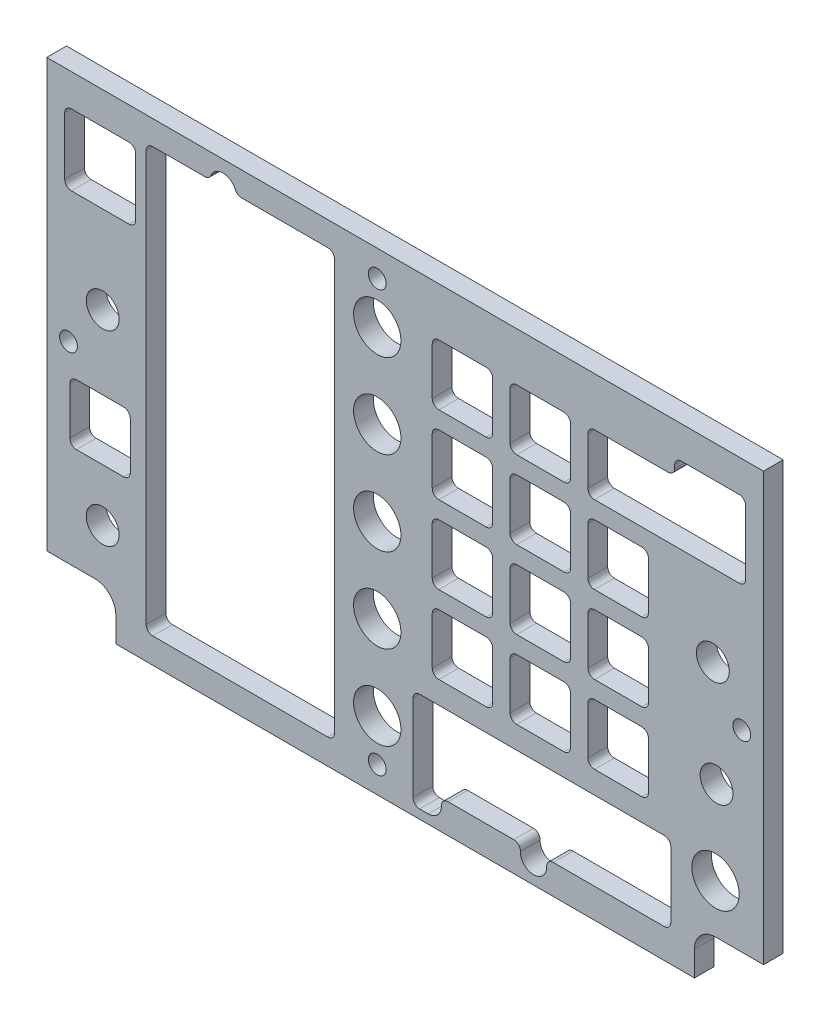
from build123d import *

# Parameters (mm, degrees)
BOSS_EXTRUDE1_DEPTH     = 4.7625
SKETCH4_R               = 3.96875
CUT_EXTRUDE2_DEPTH      = 5.7625
F_6_CLEARANCE_HOLE2_D   = 4.3053
SKETCH15_R              = 5.715
CUT_EXTRUDE8_DEPTH      = 1
CUT_EXTRUDE8_DEPTH_BACK = 5.7625


with BuildPart() as part:
    # Sketch1 → Boss-Extrude1 (new body)
    with BuildSketch(Plane.XY):
        with BuildLine():
            Line((74.93, -171.1167297), (86.51875, -171.1167297))
            Line((86.51875, -171.1167297), (86.51875, -67.9292297))
            Line((86.51875, -67.9292297), (-86.51875, -67.9292297))
            Line((-86.51875, -67.9292297), (-86.51875, -171.1167297))
            Line((-86.51875, -171.1167297), (-74.93, -171.1167297))
            ThreePointArc((-74.93, -171.1167297), (-71.337897552, -172.604627251), (-69.85, -176.1967297))
            Line((-69.85, -176.1967297), (-69.85, -182.2292297))
            Line((-69.85, -182.2292297), (69.85, -182.2292297))
            Line((69.85, -182.2292297), (69.85, -176.1967297))
            ThreePointArc((69.85, -176.1967297), (71.337897552, -172.604627251), (74.93, -171.1167297))
        make_face()
    extrude(amount=-BOSS_EXTRUDE1_DEPTH)

    # Sketch4 → Cut-Extrude2 (cut, through all)
    with BuildSketch(Plane.XY):
        with Locations((-73.025, -113.9667297)):
            Circle(SKETCH4_R)
        with Locations((-73.025, -159.0517297)):
            Circle(SKETCH4_R)
        with Locations((74.295, -113.9667297)):
            Circle(SKETCH4_R)
        with Locations((75.184, -139.0492297)):
            Circle(SKETCH4_R)
    extrude(amount=-CUT_EXTRUDE2_DEPTH, mode=Mode.SUBTRACT)

    # #6 Clearance Hole2 (through all)
    with Locations(Plane(origin=(0, 0, 1.5875), x_dir=(-1, 0, 0), z_dir=(0, 0, 1))):
        with Locations((-81.28, 124.6982297), (6.731, 175.8792297), (81.28, 124.6982297), (6.731, 74.2792297)):
            Hole(F_6_CLEARANCE_HOLE2_D / 2)

    # Sketch15 → Cut-Extrude8 (cut, two sides)
    with BuildSketch(Plane(origin=(0, 0, -4.7625), x_dir=(-1, 0, 0), z_dir=(0, 0, -1))) as cut_extrude8_sk:
        with Locations((-74.93, -159.3692297)):
            Circle(SKETCH15_R)
        with Locations((6.731, -84.4392297)):
            Circle(SKETCH15_R)
        with Locations((6.731, -104.7592297)):
            Circle(SKETCH15_R)
        with Locations((6.731, -125.0792297)):
            Circle(SKETCH15_R)
        with Locations((6.731, -145.3992297)):
            Circle(SKETCH15_R)
        with Locations((6.731, -165.7192297)):
            Circle(SKETCH15_R)
        with BuildLine():
            Line((-58.7375, -137.6522297), (-58.7375, -149.0822297))
            ThreePointArc((-58.7375, -149.0822297), (-58.272532015, -150.204761715), (-57.15, -150.6697297))
            Line((-57.15, -150.6697297), (-45.72, -150.6697297))
            ThreePointArc((-45.72, -150.6697297), (-44.597467985, -150.204761715), (-44.1325, -149.0822297))
            Line((-44.1325, -149.0822297), (-44.1325, -137.6522297))
            ThreePointArc((-44.1325, -137.6522297), (-44.597467985, -136.529697685), (-45.72, -136.0647297))
            Line((-45.72, -136.0647297), (-57.15, -136.0647297))
            ThreePointArc((-57.15, -136.0647297), (-58.272532015, -136.529697685), (-58.7375, -137.6522297))
        make_face()
        with BuildLine():
            Line((-58.7375, -118.8562297), (-58.7375, -130.2862297))
            ThreePointArc((-58.7375, -130.2862297), (-58.272532015, -131.408761715), (-57.15, -131.8737297))
            Line((-57.15, -131.8737297), (-45.72, -131.8737297))
            ThreePointArc((-45.72, -131.8737297), (-44.597467985, -131.408761715), (-44.1325, -130.2862297))
            Line((-44.1325, -130.2862297), (-44.1325, -118.8562297))
            ThreePointArc((-44.1325, -118.8562297), (-44.597467985, -117.733697685), (-45.72, -117.2687297))
            Line((-45.72, -117.2687297), (-57.15, -117.2687297))
            ThreePointArc((-57.15, -117.2687297), (-58.272532015, -117.733697685), (-58.7375, -118.8562297))
        make_face()
        with BuildLine():
            Line((-58.7375, -100.0602297), (-58.7375, -111.4902297))
            ThreePointArc((-58.7375, -111.4902297), (-58.272532015, -112.612761715), (-57.15, -113.0777297))
            Line((-57.15, -113.0777297), (-45.72, -113.0777297))
            ThreePointArc((-45.72, -113.0777297), (-44.597467985, -112.612761715), (-44.1325, -111.4902297))
            Line((-44.1325, -111.4902297), (-44.1325, -100.0602297))
            ThreePointArc((-44.1325, -100.0602297), (-44.597467985, -98.937697685), (-45.72, -98.4727297))
            Line((-45.72, -98.4727297), (-57.15, -98.4727297))
            ThreePointArc((-57.15, -98.4727297), (-58.272532015, -98.937697685), (-58.7375, -100.0602297))
        make_face()
        with BuildLine():
            Line((-45.72, -79.6767297), (-63.488214902, -79.6767297))
            ThreePointArc((-63.488214902, -79.6767297), (-64.610746917, -79.211761715), (-65.075714902, -78.0892297))
            Line((-65.075714902, -78.0892297), (-65.075714902, -77.3272297))
            ThreePointArc((-65.075714902, -77.3272297), (-65.540682887, -76.204697685), (-66.663214902, -75.7397297))
            Line((-66.663214902, -75.7397297), (-80.633214902, -75.7397297))
            ThreePointArc((-80.633214902, -75.7397297), (-81.755746917, -76.204697685), (-82.220714902, -77.3272297))
            Line((-82.220714902, -77.3272297), (-82.220714902, -92.6942297))
            ThreePointArc((-82.220714902, -92.6942297), (-81.755746917, -93.816761715), (-80.633214902, -94.2817297))
            Line((-80.633214902, -94.2817297), (-45.72, -94.2817297))
            ThreePointArc((-45.72, -94.2817297), (-44.597467985, -93.816761715), (-44.1325, -92.6942297))
            Line((-44.1325, -92.6942297), (-44.1325, -81.2642297))
            ThreePointArc((-44.1325, -81.2642297), (-44.597467985, -80.141697685), (-45.72, -79.6767297))
        make_face()
        with BuildLine():
            Line((-39.9415, -81.2642297), (-39.9415, -92.6942297))
            ThreePointArc((-39.9415, -92.6942297), (-39.476532015, -93.816761715), (-38.354, -94.2817297))
            Line((-38.354, -94.2817297), (-26.924, -94.2817297))
            ThreePointArc((-26.924, -94.2817297), (-25.801467985, -93.816761715), (-25.3365, -92.6942297))
            Line((-25.3365, -92.6942297), (-25.3365, -81.2642297))
            ThreePointArc((-25.3365, -81.2642297), (-25.801467985, -80.141697685), (-26.924, -79.6767297))
            Line((-26.924, -79.6767297), (-38.354, -79.6767297))
            ThreePointArc((-38.354, -79.6767297), (-39.476532015, -80.141697685), (-39.9415, -81.2642297))
        make_face()
        with BuildLine():
            Line((-39.9415, -100.0602297), (-39.9415, -111.4902297))
            ThreePointArc((-39.9415, -111.4902297), (-39.476532015, -112.612761715), (-38.354, -113.0777297))
            Line((-38.354, -113.0777297), (-26.924, -113.0777297))
            ThreePointArc((-26.924, -113.0777297), (-25.801467985, -112.612761715), (-25.3365, -111.4902297))
            Line((-25.3365, -111.4902297), (-25.3365, -100.0602297))
            ThreePointArc((-25.3365, -100.0602297), (-25.801467985, -98.937697685), (-26.924, -98.4727297))
            Line((-26.924, -98.4727297), (-38.354, -98.4727297))
            ThreePointArc((-38.354, -98.4727297), (-39.476532015, -98.937697685), (-39.9415, -100.0602297))
        make_face()
        with BuildLine():
            Line((-39.9415, -118.8562297), (-39.9415, -130.2862297))
            ThreePointArc((-39.9415, -130.2862297), (-39.476532015, -131.408761715), (-38.354, -131.8737297))
            Line((-38.354, -131.8737297), (-26.924, -131.8737297))
            ThreePointArc((-26.924, -131.8737297), (-25.801467985, -131.408761715), (-25.3365, -130.2862297))
            Line((-25.3365, -130.2862297), (-25.3365, -118.8562297))
            ThreePointArc((-25.3365, -118.8562297), (-25.801467985, -117.733697685), (-26.924, -117.2687297))
            Line((-26.924, -117.2687297), (-38.354, -117.2687297))
            ThreePointArc((-38.354, -117.2687297), (-39.476532015, -117.733697685), (-39.9415, -118.8562297))
        make_face()
        with BuildLine():
            Line((-39.9415, -137.6522297), (-39.9415, -149.0822297))
            ThreePointArc((-39.9415, -149.0822297), (-39.476532015, -150.204761715), (-38.354, -150.6697297))
            Line((-38.354, -150.6697297), (-26.924, -150.6697297))
            ThreePointArc((-26.924, -150.6697297), (-25.801467985, -150.204761715), (-25.3365, -149.0822297))
            Line((-25.3365, -149.0822297), (-25.3365, -137.6522297))
            ThreePointArc((-25.3365, -137.6522297), (-25.801467985, -136.529697685), (-26.924, -136.0647297))
            Line((-26.924, -136.0647297), (-38.354, -136.0647297))
            ThreePointArc((-38.354, -136.0647297), (-39.476532015, -136.529697685), (-39.9415, -137.6522297))
        make_face()
        with BuildLine():
            Line((-26.230517255, -175.1172297), (-10.349482745, -175.1172297))
            ThreePointArc((-10.349482745, -175.1172297), (-9.207149606, -175.602354423), (-8.762988497, -176.7612297))
            ThreePointArc((-8.762988497, -176.7612297), (-7.874666278, -179.078980253), (-5.59, -180.0492297))
            Line((-5.59, -180.0492297), (-3.4925, -180.0492297))
            ThreePointArc((-3.4925, -180.0492297), (-2.369967985, -179.584261715), (-1.905, -178.4617297))
            Line((-1.905, -178.4617297), (-1.905, -157.6547297))
            ThreePointArc((-1.905, -157.6547297), (-2.369967985, -156.532197685), (-3.4925, -156.0672297))
            Line((-3.4925, -156.0672297), (-62.5475, -156.0672297))
            ThreePointArc((-62.5475, -156.0672297), (-63.670032015, -156.532197685), (-64.135, -157.6547297))
            Line((-64.135, -157.6547297), (-64.135, -173.5297297))
            ThreePointArc((-64.135, -173.5297297), (-63.670032015, -174.652261715), (-62.5475, -175.1172297))
            Line((-62.5475, -175.1172297), (-35.749482745, -175.1172297))
            ThreePointArc((-35.749482745, -175.1172297), (-34.607149606, -175.602354423), (-34.162988497, -176.7612297))
            ThreePointArc((-34.162988497, -176.7612297), (-30.99, -180.0492297), (-27.817011503, -176.7612297))
            ThreePointArc((-27.817011503, -176.7612297), (-27.372850394, -175.602354423), (-26.230517255, -175.1172297))
        make_face()
        with BuildLine():
            Line((-6.5405, -149.0822297), (-6.5405, -137.6522297))
            ThreePointArc((-6.5405, -137.6522297), (-7.005467985, -136.529697685), (-8.128, -136.0647297))
            Line((-8.128, -136.0647297), (-19.558, -136.0647297))
            ThreePointArc((-19.558, -136.0647297), (-20.680532015, -136.529697685), (-21.1455, -137.6522297))
            Line((-21.1455, -137.6522297), (-21.1455, -149.0822297))
            ThreePointArc((-21.1455, -149.0822297), (-20.680532015, -150.204761715), (-19.558, -150.6697297))
            Line((-19.558, -150.6697297), (-8.128, -150.6697297))
            ThreePointArc((-8.128, -150.6697297), (-7.005467985, -150.204761715), (-6.5405, -149.0822297))
        make_face()
        with BuildLine():
            Line((-6.5405, -130.2862297), (-6.5405, -118.8562297))
            ThreePointArc((-6.5405, -118.8562297), (-7.005467985, -117.733697685), (-8.128, -117.2687297))
            Line((-8.128, -117.2687297), (-19.558, -117.2687297))
            ThreePointArc((-19.558, -117.2687297), (-20.680532015, -117.733697685), (-21.1455, -118.8562297))
            Line((-21.1455, -118.8562297), (-21.1455, -130.2862297))
            ThreePointArc((-21.1455, -130.2862297), (-20.680532015, -131.408761715), (-19.558, -131.8737297))
            Line((-19.558, -131.8737297), (-8.128, -131.8737297))
            ThreePointArc((-8.128, -131.8737297), (-7.005467985, -131.408761715), (-6.5405, -130.2862297))
        make_face()
        with BuildLine():
            Line((-21.1455, -100.0602297), (-21.1455, -111.4902297))
            ThreePointArc((-21.1455, -111.4902297), (-20.680532015, -112.612761715), (-19.558, -113.0777297))
            Line((-19.558, -113.0777297), (-8.128, -113.0777297))
            ThreePointArc((-8.128, -113.0777297), (-7.005467985, -112.612761715), (-6.5405, -111.4902297))
            Line((-6.5405, -111.4902297), (-6.5405, -100.0602297))
            ThreePointArc((-6.5405, -100.0602297), (-7.005467985, -98.937697685), (-8.128, -98.4727297))
            Line((-8.128, -98.4727297), (-19.558, -98.4727297))
            ThreePointArc((-19.558, -98.4727297), (-20.680532015, -98.937697685), (-21.1455, -100.0602297))
        make_face()
        with BuildLine():
            Line((-21.1455, -81.2642297), (-21.1455, -92.6942297))
            ThreePointArc((-21.1455, -92.6942297), (-20.680532015, -93.816761715), (-19.558, -94.2817297))
            Line((-19.558, -94.2817297), (-8.128, -94.2817297))
            ThreePointArc((-8.128, -94.2817297), (-7.005467985, -93.816761715), (-6.5405, -92.6942297))
            Line((-6.5405, -92.6942297), (-6.5405, -81.2642297))
            ThreePointArc((-6.5405, -81.2642297), (-7.005467985, -80.141697685), (-8.128, -79.6767297))
            Line((-8.128, -79.6767297), (-19.558, -79.6767297))
            ThreePointArc((-19.558, -79.6767297), (-20.680532015, -80.141697685), (-21.1455, -81.2642297))
        make_face()
        with BuildLine():
            Line((39.53055491, -73.7922297), (18.6555, -73.7922297))
            ThreePointArc((18.6555, -73.7922297), (17.532967985, -74.257197685), (17.068, -75.3797297))
            Line((17.068, -75.3797297), (17.068, -174.5247297))
            ThreePointArc((17.068, -174.5247297), (17.532967985, -175.647261715), (18.6555, -176.1122297))
            Line((18.6555, -176.1122297), (60.9425, -176.1122297))
            ThreePointArc((60.9425, -176.1122297), (62.065032015, -175.647261715), (62.53, -174.5247297))
            Line((62.53, -174.5247297), (62.53, -75.3797297))
            ThreePointArc((62.53, -75.3797297), (62.065032015, -74.257197685), (60.9425, -73.7922297))
            Line((60.9425, -73.7922297), (48.34944509, -73.7922297))
            ThreePointArc((48.34944509, -73.7922297), (47.464029698, -73.522377541), (46.87963006, -72.804563033))
            ThreePointArc((46.87963006, -72.804563033), (43.94, -70.8292297), (41.00036994, -72.804563033))
            ThreePointArc((41.00036994, -72.804563033), (40.415970302, -73.522377541), (39.53055491, -73.7922297))
        make_face()
        with BuildLine():
            Line((65.040037257, -77.310707272), (65.040037257, -91.280707272))
            ThreePointArc((65.040037257, -91.280707272), (65.505005242, -92.403239287), (66.627537257, -92.868207272))
            Line((66.627537257, -92.868207272), (80.597537257, -92.868207272))
            ThreePointArc((80.597537257, -92.868207272), (81.720069272, -92.403239287), (82.185037257, -91.280707272))
            Line((82.185037257, -91.280707272), (82.185037257, -77.310707272))
            ThreePointArc((82.185037257, -77.310707272), (81.720069272, -76.188175257), (80.597537257, -75.723207272))
            Line((80.597537257, -75.723207272), (66.627537257, -75.723207272))
            ThreePointArc((66.627537257, -75.723207272), (65.505005242, -76.188175257), (65.040037257, -77.310707272))
        make_face()
        with BuildLine():
            Line((80.9625, -144.7642297), (80.9625, -133.3342297))
            ThreePointArc((80.9625, -133.3342297), (80.497532015, -132.211697685), (79.375, -131.7467297))
            Line((79.375, -131.7467297), (67.945, -131.7467297))
            ThreePointArc((67.945, -131.7467297), (66.822467985, -132.211697685), (66.3575, -133.3342297))
            Line((66.3575, -133.3342297), (66.3575, -144.7642297))
            ThreePointArc((66.3575, -144.7642297), (66.822467985, -145.886761715), (67.945, -146.3517297))
            Line((67.945, -146.3517297), (79.375, -146.3517297))
            ThreePointArc((79.375, -146.3517297), (80.497532015, -145.886761715), (80.9625, -144.7642297))
        make_face()
    extrude(amount=CUT_EXTRUDE8_DEPTH, mode=Mode.SUBTRACT)
    extrude(cut_extrude8_sk.sketch, amount=-CUT_EXTRUDE8_DEPTH_BACK, mode=Mode.SUBTRACT)


solid = part.part
